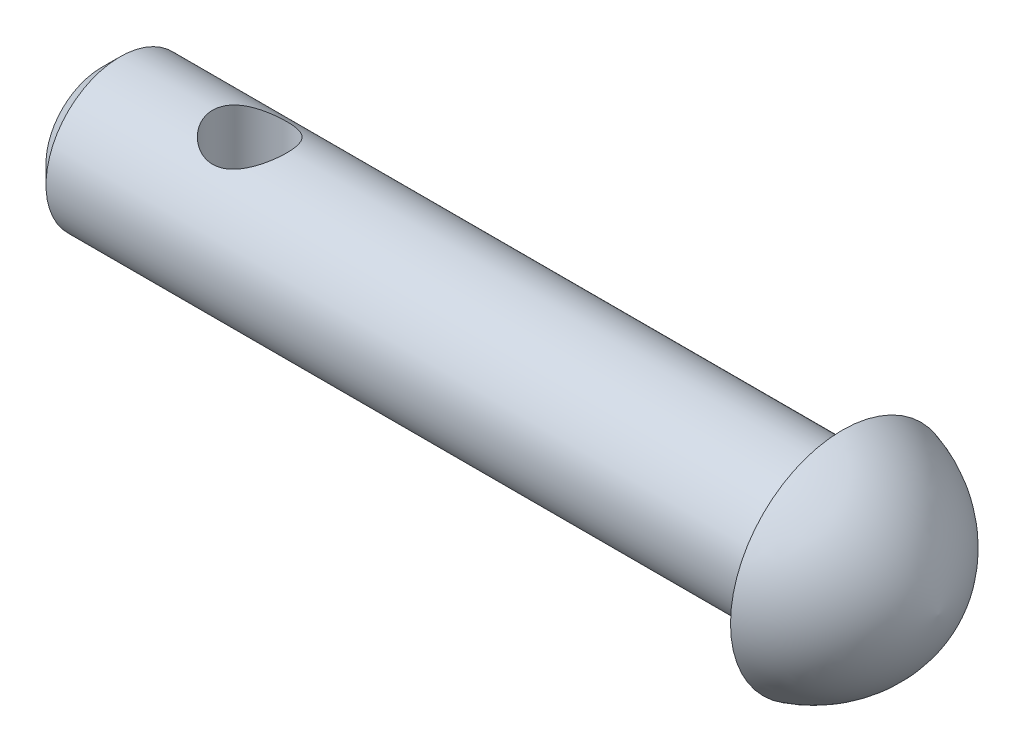
from build123d import *

# Parameters (mm, degrees)
SKETCH1_R               = 2
BOSS_EXTRUDE1_DEPTH     = 20
CHAMFER1_SIZE           = 0.5
SKETCH2_R               = 1
CUT_EXTRUDE1_DEPTH      = 3
CUT_EXTRUDE1_DEPTH_BACK = 3


with BuildPart() as part:
    # Sketch1 → Boss-Extrude1 (new body)
    with BuildSketch(Plane(origin=(0, 0, 0), x_dir=(0, 0, -1), z_dir=(1, 0, 0))):
        Circle(SKETCH1_R)
    extrude(amount=BOSS_EXTRUDE1_DEPTH)

    # Chamfer1
    chamfer1_edges = [part.edges().sort_by_distance(p)[0] for p in [
        (0, 0, 2),
    ]]
    chamfer(chamfer1_edges, length=CHAMFER1_SIZE)

    # Sketch2 → Cut-Extrude1 (cut, two sides)
    with BuildSketch(Plane(origin=(0, 0, 0), x_dir=(1, 0, 0), z_dir=(0, 1, 0))) as cut_extrude1_sk:
        with Locations((4, 0)):
            Circle(SKETCH2_R)
    extrude(amount=CUT_EXTRUDE1_DEPTH, mode=Mode.SUBTRACT)
    extrude(cut_extrude1_sk.sketch, amount=-CUT_EXTRUDE1_DEPTH_BACK, mode=Mode.SUBTRACT)

    # Sketch4 → Revolve1 (revolve)
    with BuildSketch(Plane.XY):
        with BuildLine():
            Line((20, 3.017004448), (20, 0))
            Line((20, 0), (22.6, 0))
            ThreePointArc((22.6, 0), (21.755214952, 1.900798256), (20, 3.017004448))
        make_face()
    revolve(axis=Axis((19, 0, 0), (1, 0, 0)))


solid = part.part
